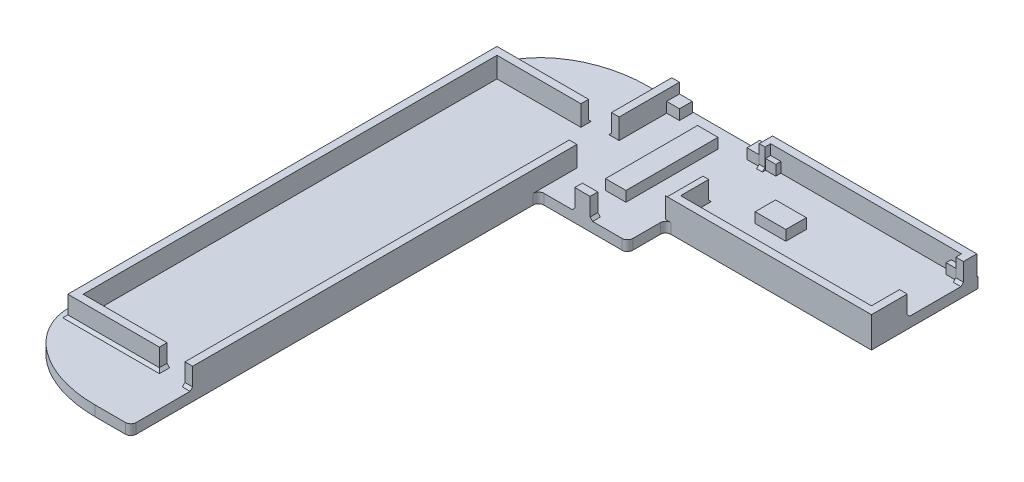
from build123d import *

# Parameters (mm, degrees)
BOSS_EXTRUDE1_DEPTH   = 4
SKETCH1_W             = 1.5
SKETCH1_H             = 11.783355086
BOSS_EXTRUDE1_2_DEPTH = 4
SKETCH1_H_2           = 75.118771789
BOSS_EXTRUDE1_3_DEPTH = 4
BOSS_EXTRUDE1_4_DEPTH = 4
BOSS_EXTRUDE1_5_DEPTH = 4
SKETCH1_W_2           = 3
SKETCH1_H_3           = 1.5
BOSS_EXTRUDE1_6_DEPTH = 4
BOSS_EXTRUDE2_DEPTH   = 2
SKETCH5_W             = 2.5
SKETCH5_H             = 2.5
SKETCH5_W_2           = 2
SKETCH5_H_2           = 1
SKETCH5_W_3           = 4
SKETCH5_H_3           = 18
SKETCH5_W_4           = 6
SKETCH5_H_4           = 4
BOSS_EXTRUDE3_DEPTH   = 2
CHAMFER1_SIZE         = 0.5


with BuildPart() as part:
    # Sketch1 → Boss-Extrude1 (new body)
    with BuildSketch(Plane(origin=(0, 0, 0), x_dir=(1, 0, 0), z_dir=(0, 1, 0))):
        Polygon((-78.405339878, 40.481228211), (-62.005339878, 40.481228211), (-62.005339878, 41.981228211), (-79.905339878, 41.981228211), (-79.905339878, -41.918771789), (-62.005339878, -41.918771789), (-62.005339878, -40.418771789), (-78.405339878, -40.418771789), align=None)
    extrude(amount=BOSS_EXTRUDE1_DEPTH)



with BuildPart() as body_2:
    # Sketch1 → Boss-Extrude1 2 (new body)
    with BuildSketch(Plane(origin=(0, 0, 0), x_dir=(1, 0, 0), z_dir=(0, 1, 0))):
        with Locations((-56.76645947, 47.872905754)):
            Rectangle(SKETCH1_W, SKETCH1_H)
    extrude(amount=BOSS_EXTRUDE1_2_DEPTH)


with BuildPart() as body_3:
    # Sketch1 → Boss-Extrude1 3 (new body)
    with BuildSketch(Plane(origin=(0, 0, 0), x_dir=(1, 0, 0), z_dir=(0, 1, 0))):
        with Locations((-56.255339878, -4.359385895)):
            Rectangle(SKETCH1_W, SKETCH1_H_2)
    extrude(amount=BOSS_EXTRUDE1_3_DEPTH)


with BuildPart() as body_4:
    # Sketch1 → Boss-Extrude1 4 (new body)
    with BuildSketch(Plane(origin=(0, 0, 0), x_dir=(1, 0, 0), z_dir=(0, 1, 0))):
        Polygon((-38.191144671, 33.2), (-38.191144671, 33.164583297), (2.108855329, 33.164583297), (2.108855329, 40.155086191), (0.608855329, 40.155086191), (0.608855329, 34.664583297), (-36.691144671, 34.664583297), (-36.691144671, 40.155086191), (-37.81645947, 40.155086191), (-37.81645947, 33.2), align=None)
    extrude(amount=BOSS_EXTRUDE1_4_DEPTH)


with BuildPart() as body_5:
    # Sketch1 → Boss-Extrude1 5 (new body)
    with BuildSketch(Plane(origin=(0, 0, 0), x_dir=(1, 0, 0), z_dir=(0, 1, 0))):
        Polygon((-36.691144671, 52.264583297), (0.608855329, 52.264583297), (0.608855329, 51.155086191), (2.108855329, 51.155086191), (2.108855329, 53.764583297), (-37.81645947, 53.764583297), (-37.81645947, 51.155086191), (-36.691144671, 51.155086191), align=None)
    extrude(amount=BOSS_EXTRUDE1_5_DEPTH)


with BuildPart() as body_6:
    # Sketch1 → Boss-Extrude1 6 (new body)
    with BuildSketch(Plane(origin=(0, 0, 0), x_dir=(1, 0, 0), z_dir=(0, 1, 0))):
        with Locations((-46.91645947, 26.45)):
            Rectangle(SKETCH1_W_2, SKETCH1_H_3)
    extrude(amount=BOSS_EXTRUDE1_6_DEPTH)


with BuildPart() as part_1:
    add(part.part)

    add(body_2.part)  # Boss-Extrude2 merges body 2

    add(body_3.part)  # Boss-Extrude2 merges body 3

    add(body_4.part)  # Boss-Extrude2 merges body 4

    add(body_5.part)  # Boss-Extrude2 merges body 5

    add(body_6.part)  # Boss-Extrude2 merges body 6
    # Sketch2 → Boss-Extrude2 (add)
    with BuildSketch(Plane(origin=(0, 0, 0), x_dir=(1, 0, 0), z_dir=(0, 1, 0))):
        with BuildLine():
            Line((2.108855329, 33.164583297), (2.108855329, 54))
            Line((2.108855329, 54), (-62.5, 54))
            add(Edge.make_bspline(
                [(-81.5, 40), (-81.502243344, 41.173845434), (-81.047727895, 43.124370376), (-80.54933313, 44.398501715), (-80.092349724, 45.289360005), (-79.662158352, 46.003599412), (-79.23101892, 46.6298604), (-78.635262131, 47.400336774), (-77.699592936, 48.420815991), (-76.62065129, 49.371224085), (-75.777066539, 50.008965255), (-75.040717172, 50.51071787), (-74.379360639, 50.920225906), (-73.506270835, 51.414278971), (-72.232742284, 52.035673953), (-70.694700828, 52.643574158), (-69.042987408, 53.155056852), (-67.458196566, 53.527596425), (-64.612663916, 54.000370418), (-62.5, 54)],
                knots=[0, 0, 0, 0.09375, 0.15625, 0.203125, 0.234375, 0.265625, 0.296875, 0.34375, 0.40625, 0.453125, 0.484375, 0.515625, 0.546875, 0.59375, 0.65625, 0.71875, 0.78125, 0.84375, 1, 1, 1], degree=2))
            Line((-81.5, 40), (-81.5, -40))
            add(Edge.make_bspline(
                [(-62.5, -54), (-64.618902003, -54.0002947), (-67.472295819, -53.524829059), (-69.063795556, -53.149419159), (-70.709213964, -52.638392619), (-72.243956614, -52.030656852), (-73.514824803, -51.409674441), (-74.386323364, -50.916027289), (-75.046726548, -50.506800365), (-75.781311966, -50.005949538), (-76.623163869, -49.369184511), (-77.700208559, -48.420059301), (-78.634474848, -47.401139234), (-79.230307159, -46.630574159), (-79.658424233, -46.009526136), (-80.105053847, -45.269217428), (-80.571288214, -44.360595976), (-81.072895683, -43.06600328), (-81.499778686, -41.179608093), (-81.5, -40)],
                knots=[0, 0, 0, 0.15625, 0.21875, 0.28125, 0.34375, 0.40625, 0.453125, 0.484375, 0.515625, 0.546875, 0.59375, 0.65625, 0.703125, 0.734375, 0.765625, 0.796875, 0.84375, 0.90625, 1, 1, 1], degree=2))
            Line((-62.5, -54), (-56.539545182, -54))
            ThreePointArc((-56.539545182, -54), (-55.808251599, -53.69708828), (-55.505339878, -52.965794696))
            Line((-55.505339878, -52.965794696), (-55.505339878, 24.665794696))
            ThreePointArc((-55.505339878, 24.665794696), (-55.202428158, 25.39708828), (-54.471134574, 25.7))
            Line((-54.471134574, 25.7), (-39.150664774, 25.7))
            ThreePointArc((-39.150664774, 25.7), (-38.41937119, 26.00291172), (-38.11645947, 26.734205304))
            Line((-38.11645947, 26.734205304), (-38.11645947, 32.130377993))
            ThreePointArc((-38.11645947, 32.130377993), (-37.813547749, 32.861671577), (-37.082254166, 33.164583297))
            Line((-37.082254166, 33.164583297), (2.108855329, 33.164583297))
        make_face()
    extrude(amount=-BOSS_EXTRUDE2_DEPTH)

    # Sketch5 → Boss-Extrude3 (add)
    with BuildSketch(Plane(origin=(0, 0, 0), x_dir=(-1, 0, 0), z_dir=(0, -1, 0))):
        with Locations((54.76645947, 52.514583297)):
            Rectangle(SKETCH5_W, SKETCH5_H)
        with Locations((35.691144671, 51.764583297)):
            Rectangle(SKETCH5_W_2, SKETCH5_H_2)
        with Locations((46.91645947, 41.2)):
            Rectangle(SKETCH5_W_3, SKETCH5_H_3)
        with Locations((39.06645947, 52.514583297)):
            Rectangle(SKETCH5_W, SKETCH5_H)
        with Locations((35.691144671, 35.164583297)):
            Rectangle(SKETCH5_W_2, SKETCH5_H_2)
        with Locations((0.391144671, 51.764583297)):
            Rectangle(SKETCH5_W_2, SKETCH5_H_2)
        with Locations((0.391144671, 35.164583297)):
            Rectangle(SKETCH5_W_2, SKETCH5_H_2)
        with Locations((25.685282836, 43.226347046)):
            Rectangle(SKETCH5_W_4, SKETCH5_H_4)
    extrude(amount=-BOSS_EXTRUDE3_DEPTH)

    # Chamfer1
    chamfer1_edges = [part_1.edges().sort_by_distance(p)[0] for p in [
        (-37.25380207, 0, -40.155086191),
        (-37.25380207, 0, -51.155086191),
        (1.358855329, 0, -40.155086191),
        (1.358855329, 0, -51.155086191),
        (-45.41645947, 0, -26.45),
        (-48.41645947, 0, -26.45),
        (-56.255339878, 0, 41.918771789),
        (-57.51645947, 0, -47.872905754),
        (-62.005339878, 0, 41.168771789),
        (-70.955339878, 0, 41.918771789),
        (-79.905339878, 0, -0.031228211),
        (-70.955339878, 0, -41.981228211),
    ]]
    chamfer(chamfer1_edges, length=CHAMFER1_SIZE)


solid = part_1.part
